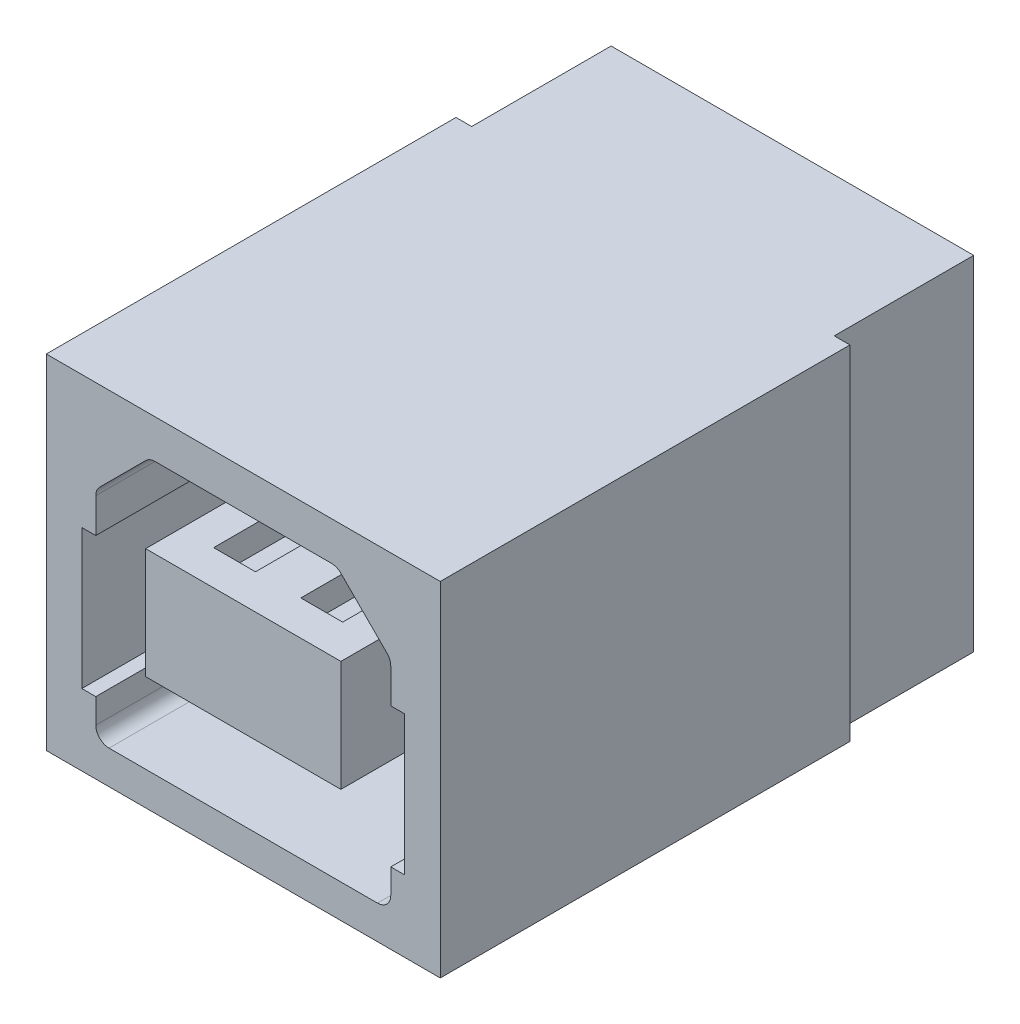
from build123d import *

# Parameters (mm, degrees)
BOSS_EXTRU_1_DEPTH      = 9.85
ESQUISSE3_W             = 5.6
ESQUISSE3_H             = 3.18
ENL_V_MAT_EXTRU_1_DEPTH = 8.38
ESQUISSE4_W             = 1
ESQUISSE4_H             = 8.25
ESQUISSE4_H_2           = 9.75
BOSS_EXTRU_2_DEPTH      = 0.83
ENL_V_START             = 1
ESQUISSE5_W             = 1.2
ESQUISSE5_H             = 0.75
ENL_V_MAT_EXTRU_2_DEPTH = 14.75
ESQUISSE6_W             = 1.2
ESQUISSE6_H             = 6.44
ENL_V_MAT_EXTRU_3_DEPTH = 1.3
ENL_V_MAT_EXTRU_7_DEPTH = 1.3


with BuildPart() as part:
    # Esquisse1 → Boss.-Extru.1 (new body)
    with BuildSketch(Plane(origin=(0, 0, 0), x_dir=(1, 0, 0), z_dir=(0, 1, 0))):
        Polygon((-5.65, 11.75), (-5.65, 0), (5.65, 0), (5.65, 11.75), (5.2, 11.75), (5.2, 15.75), (-5.2, 15.75), (-5.2, 11.75), align=None)
    extrude(amount=BOSS_EXTRU_1_DEPTH)

    # Esquisse3 → Enlèv. mat.-Extru.1 (cut)
    with BuildSketch(Plane.XY):
        with BuildLine():
            Line((-4.63, 2.05), (-4.23, 2.05))
            Line((-4.23, 2.05), (-4.23, 1.34))
            ThreePointArc((-4.23, 1.34), (-4.118700577, 1.071299423), (-3.85, 0.96))
            Line((-3.85, 0.96), (3.85, 0.96))
            ThreePointArc((3.85, 0.96), (4.118700577, 1.071299423), (4.23, 1.34))
            Line((4.23, 1.34), (4.23, 2.05))
            Line((4.23, 2.05), (4.63, 2.05))
            Line((4.63, 2.05), (4.63, 6.05))
            Line((4.63, 6.05), (4.23, 6.05))
            Line((4.23, 6.05), (4.23, 7.04))
            ThreePointArc((4.23, 7.04), (4.201074222, 7.185419704), (4.118700577, 7.308700577))
            Line((4.118700577, 7.308700577), (2.798700577, 8.628700577))
            ThreePointArc((2.798700577, 8.628700577), (2.675419704, 8.711074222), (2.53, 8.74))
            Line((2.53, 8.74), (-2.53, 8.74))
            ThreePointArc((-2.53, 8.74), (-2.675419704, 8.711074222), (-2.798700577, 8.628700577))
            Line((-2.798700577, 8.628700577), (-4.118700577, 7.308700577))
            ThreePointArc((-4.118700577, 7.308700577), (-4.201074222, 7.185419704), (-4.23, 7.04))
            Line((-4.23, 7.04), (-4.23, 6.05))
            Line((-4.23, 6.05), (-4.63, 6.05))
            Line((-4.63, 6.05), (-4.63, 2.05))
        make_face()
        with Locations((0, 4.85)):
            Rectangle(ESQUISSE3_W, ESQUISSE3_H, mode=Mode.SUBTRACT)
    extrude(amount=-ENL_V_MAT_EXTRU_1_DEPTH, mode=Mode.SUBTRACT)

    # Esquisse4 → Boss.-Extru.2 (add)
    with BuildSketch(Plane.XZ):
        with Locations((0, -11.625)):
            Rectangle(ESQUISSE4_W, ESQUISSE4_H)
        with Locations((-3.75, -10.875)):
            Rectangle(ESQUISSE4_W, ESQUISSE4_H_2)
        with Locations((3.75, -10.875)):
            Rectangle(ESQUISSE4_W, ESQUISSE4_H_2)
    extrude(amount=BOSS_EXTRU_2_DEPTH)

    # Esquisse5 → Enlèv. mat.-Extru.2 (cut)
    with BuildSketch(Plane(origin=(0, 0, 0), x_dir=(-1, 0, 0), z_dir=(0, 0, -1)).offset(ENL_V_START)):
        with Locations((1.25, 6.065)):
            Rectangle(ESQUISSE5_W, ESQUISSE5_H)
        with Locations((1.25, 3.635)):
            Rectangle(ESQUISSE5_W, ESQUISSE5_H)
        with Locations((-1.25, 3.635)):
            Rectangle(ESQUISSE5_W, ESQUISSE5_H)
        with Locations((-1.25, 6.065)):
            Rectangle(ESQUISSE5_W, ESQUISSE5_H)
    extrude(amount=ENL_V_MAT_EXTRU_2_DEPTH, mode=Mode.SUBTRACT)

    # Esquisse6 → Enlèv. mat.-Extru.3 (cut)
    with BuildSketch(Plane(origin=(0, 0, -15.75), x_dir=(-1, 0, 0), z_dir=(0, 0, -1))):
        with Locations((-1.25, 3.22)):
            Rectangle(ESQUISSE6_W, ESQUISSE6_H)
        with Locations((1.25, 3.22)):
            Rectangle(ESQUISSE6_W, ESQUISSE6_H)
    extrude(amount=-ENL_V_MAT_EXTRU_3_DEPTH, mode=Mode.SUBTRACT)

    # Esquisse7 → Enlèv. mat.-Extru.7 (cut)
    with BuildSketch(Plane(origin=(0, 0, -14.45), x_dir=(-1, 0, 0), z_dir=(0, 0, -1))):
        Polygon((-1.85, 4.01), (-0.65, 4.01), (-0.65, 2.26), (-0.95, 2.26), (-0.95, 0), (-1.55, 0), (-1.55, 2.26), (-1.85, 2.26), align=None)
        Polygon((0.65, 2.26), (0.65, 4.01), (1.85, 4.01), (1.85, 2.26), (1.55, 2.26), (1.55, 0), (0.95, 0), (0.95, 2.26), align=None)
    extrude(amount=-ENL_V_MAT_EXTRU_7_DEPTH, mode=Mode.SUBTRACT)


solid = part.part
